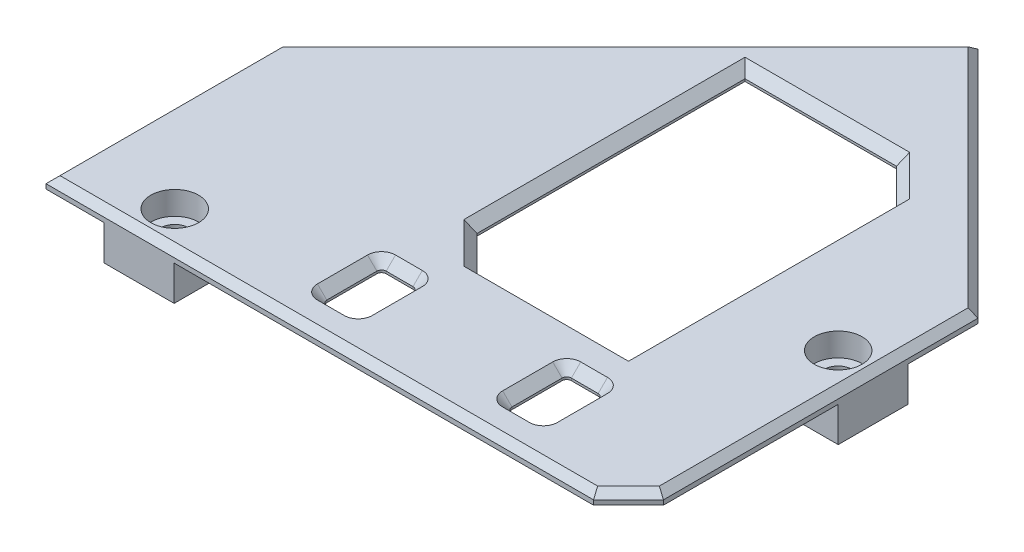
from build123d import *

# Parameters (mm, degrees)
EXTRUDE_1_DEPTH     = 1
CHAMFER_2_SIZE      = 3
CHAMFER_1_SIZE      = 0.6
SKETCH_2_W          = 16
SKETCH_2_H          = 26
CUT_EXTRUDE_1_DEPTH = 10
CHAMFER_3_SIZE      = 3
CHAMFER_4_SIZE      = 0.8
SKETCH_3_W          = 6
SKETCH_3_H          = 6
EXTRUDE_2_DEPTH     = 3
SKETCH_4_R          = 1.2
CUT_EXTRUDE_2_DEPTH = 5
SKETCH_5_R          = 2.05
CUT_EXTRUDE_3_DEPTH = 2
FILLET_1_R          = 2
SKETCH_7_W          = 3.1
SKETCH_7_H          = 5.1
CUT_EXTRUDE_4_DEPTH = 2
FILLET_2_R          = 0.4
CHAMFER_5_SIZE      = 0.8


with BuildPart() as part:
    # 草图1 → 凸台-拉伸1 (new body)
    with BuildSketch(Plane(origin=(0, 0, 0), x_dir=(1, 0, 0), z_dir=(0, 1, 0))):
        Polygon((0, 0), (50, 0), (50, 30), (30, 50), (0, 20), align=None)
    extrude(amount=EXTRUDE_1_DEPTH)

    # 倒角2
    chamfer_2_edges = [part.edges().sort_by_distance(p)[0] for p in [
        (50, 0.5, 0),
    ]]
    chamfer(chamfer_2_edges, length=CHAMFER_2_SIZE)

    # 倒角1
    chamfer_1_edges = [part.edges().sort_by_distance(p)[0] for p in [
        (40, 1, -40),
        (50, 1, -16.5),
        (48.5, 1, -1.5),
        (15, 1, -35),
        (0, 1, -10),
        (23.5, 1, 0),
    ]]
    chamfer(chamfer_1_edges, length=CHAMFER_1_SIZE)

    # 草图2 → 切除-拉伸1 (cut)
    with BuildSketch(Plane(origin=(0, 1, 0), x_dir=(1, 0, 0), z_dir=(0, 1, 0))):
        with Locations((30, 25)):
            Rectangle(SKETCH_2_W, SKETCH_2_H)
    extrude(amount=-CUT_EXTRUDE_1_DEPTH, mode=Mode.SUBTRACT)

    # 倒角3
    chamfer_3_edges = [part.edges().sort_by_distance(p)[0] for p in [
        (22, 0.5, -12),
        (38, 0.5, -38),
    ]]
    chamfer(chamfer_3_edges, length=CHAMFER_3_SIZE)

    # 倒角4
    chamfer_4_edges = [part.edges().sort_by_distance(p)[0] for p in [
        (22, 1, -26.5),
        (38, 1, -23.5),
        (28.5, 1, -38),
        (31.5, 1, -12),
        (36.5, 1, -36.5),
        (23.5, 1, -13.5),
    ]]
    chamfer(chamfer_4_edges, length=CHAMFER_4_SIZE)

    # 草图3 → 凸台-拉伸2 (add)
    with BuildSketch(Plane.XZ):
        with Locations((8, -3)):
            Rectangle(SKETCH_3_W, SKETCH_3_H)
        with Locations((47, -21)):
            Rectangle(SKETCH_3_W, SKETCH_3_H)
    extrude(amount=EXTRUDE_2_DEPTH)

    # 草图4 → 切除-拉伸2 (cut, through all)
    with BuildSketch(Plane.XZ.offset(3)):
        with Locations((8, -3.05)):
            Circle(SKETCH_4_R)
        with Locations((47, -21)):
            Circle(SKETCH_4_R)
    extrude(amount=-CUT_EXTRUDE_2_DEPTH, mode=Mode.SUBTRACT)

    # 草图5 → 切除-拉伸3 (cut)
    with BuildSketch(Plane(origin=(0, 1, 0), x_dir=(1, 0, 0), z_dir=(0, 1, 0))):
        with Locations((8, 3.05)):
            Circle(SKETCH_5_R)
        with Locations((47, 21)):
            Circle(SKETCH_5_R)
    extrude(amount=-CUT_EXTRUDE_3_DEPTH, mode=Mode.SUBTRACT)

    # 圆角1
    fillet_1_edges = [part.edges().sort_by_distance(p)[0] for p in [
        (5, -1.5, -6),
        (11, -1.5, -6),
        (44, -1.5, -18),
        (44, -1.5, -24),
    ]]
    fillet(fillet_1_edges, radius=FILLET_1_R)

    # 草图7 → 切除-拉伸4 (cut)
    with BuildSketch(Plane(origin=(0, 1, 0), x_dir=(1, 0, 0), z_dir=(0, 1, 0))):
        with Locations((37.947463912, 5.75)):
            Rectangle(SKETCH_7_W, SKETCH_7_H)
        with Locations((22.050353573, 5.75)):
            Rectangle(SKETCH_7_W, SKETCH_7_H)
    extrude(amount=-CUT_EXTRUDE_4_DEPTH, mode=Mode.SUBTRACT)

    # 圆角2
    fillet_2_edges = [part.edges().sort_by_distance(p)[0] for p in [
        (20.500353573, 0.5, -8.3),
        (23.600353573, 0.5, -8.3),
        (23.600353573, 0.5, -3.2),
        (20.500353573, 0.5, -3.2),
        (39.497463912, 0.5, -3.2),
        (36.397463912, 0.5, -3.2),
        (36.397463912, 0.5, -8.3),
        (39.497463912, 0.5, -8.3),
    ]]
    fillet(fillet_2_edges, radius=FILLET_2_R)

    # 倒角5
    chamfer_5_edges = [part.edges().sort_by_distance(p)[0] for p in [
        (37.947463912, 1, -3.2),
        (36.397463912, 1, -5.75),
        (37.947463912, 1, -8.3),
        (39.497463912, 1, -5.75),
        (23.600353573, 1, -5.75),
        (22.050353573, 1, -3.2),
        (22.050353573, 1, -8.3),
        (20.500353573, 1, -5.75),
        (36.514621199, 1, -3.317157288),
        (36.514621199, 1, -8.182842712),
        (39.380306624, 1, -8.182842712),
        (39.380306624, 1, -3.317157288),
        (23.483196285, 1, -3.317157288),
        (23.483196285, 1, -8.182842712),
        (20.61751086, 1, -8.182842712),
        (20.61751086, 1, -3.317157288),
    ]]
    chamfer(chamfer_5_edges, length=CHAMFER_5_SIZE)


solid = part.part
